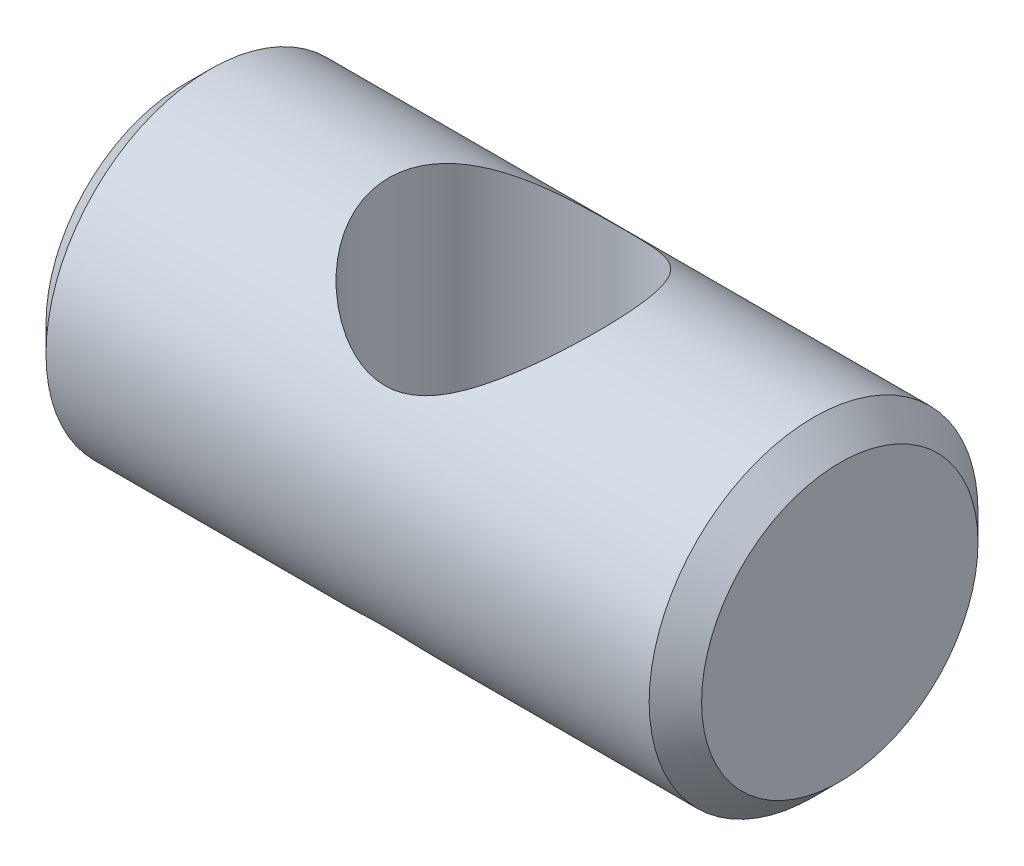
from build123d import *

# Parameters (mm, degrees)
SKETCH1_R               = 4.765
BOSS_EXTRUDE1_DEPTH     = 9.5
CHAMFER1_SIZE           = 0.76
SKETCH2_R               = 3.43
CUT_EXTRUDE1_DEPTH      = 5.765
CUT_EXTRUDE1_DEPTH_BACK = 5.765


with BuildPart() as part:
    # Sketch1 → Boss-Extrude1 (new body, symmetric)
    with BuildSketch(Plane(origin=(0, 0, 0), x_dir=(0, 0, -1), z_dir=(1, 0, 0))):
        Circle(SKETCH1_R)
    extrude(amount=BOSS_EXTRUDE1_DEPTH, both=True)

    # Chamfer1
    chamfer1_edges = [part.edges().sort_by_distance(p)[0] for p in [
        (-9.5, 0, 4.765),
        (9.5, 0, 4.765),
    ]]
    chamfer(chamfer1_edges, length=CHAMFER1_SIZE)

    # Sketch2 → Cut-Extrude1 (cut, two sides)
    with BuildSketch(Plane(origin=(0, 0, 0), x_dir=(1, 0, 0), z_dir=(0, 1, 0))) as cut_extrude1_sk:
        with Locations((0, -0.25)):
            Circle(SKETCH2_R)
    extrude(amount=CUT_EXTRUDE1_DEPTH, mode=Mode.SUBTRACT)
    extrude(cut_extrude1_sk.sketch, amount=-CUT_EXTRUDE1_DEPTH_BACK, mode=Mode.SUBTRACT)


solid = part.part
